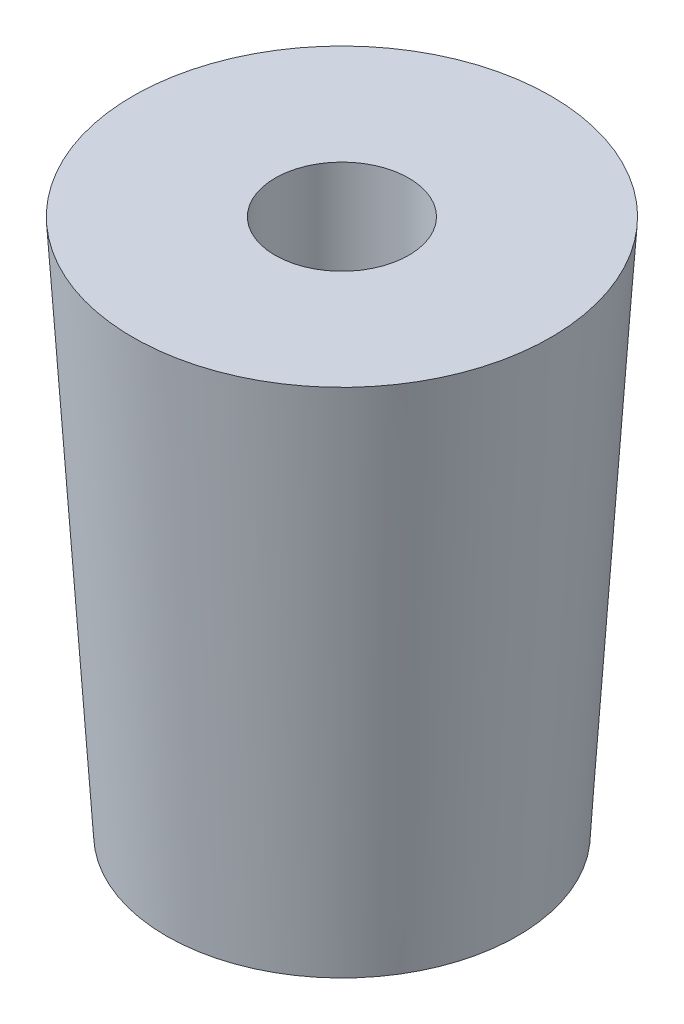
from build123d import *

# Parameters (mm, degrees)
SKETCH3_R          = 3.175
CUT_EXTRUDE1_DEPTH = 26.4


with BuildPart() as part:
    # Sketch2 → Revolve1 (revolve)
    with BuildSketch(Plane(origin=(0, 0, 0), x_dir=(0, 0, -1), z_dir=(1, 0, 0))):
        Polygon((0, 0), (8.334375, 0), (9.921875, 25.4), (0, 25.4), align=None)
    revolve(axis=Axis((0, 0, 0), (0, 1, 0)))

    # Sketch3 → Cut-Extrude1 (cut, through all)
    with BuildSketch(Plane(origin=(0, 25.4, 0), x_dir=(1, 0, 0), z_dir=(0, 1, 0))):
        Circle(SKETCH3_R)
    extrude(amount=-CUT_EXTRUDE1_DEPTH, mode=Mode.SUBTRACT)


solid = part.part
